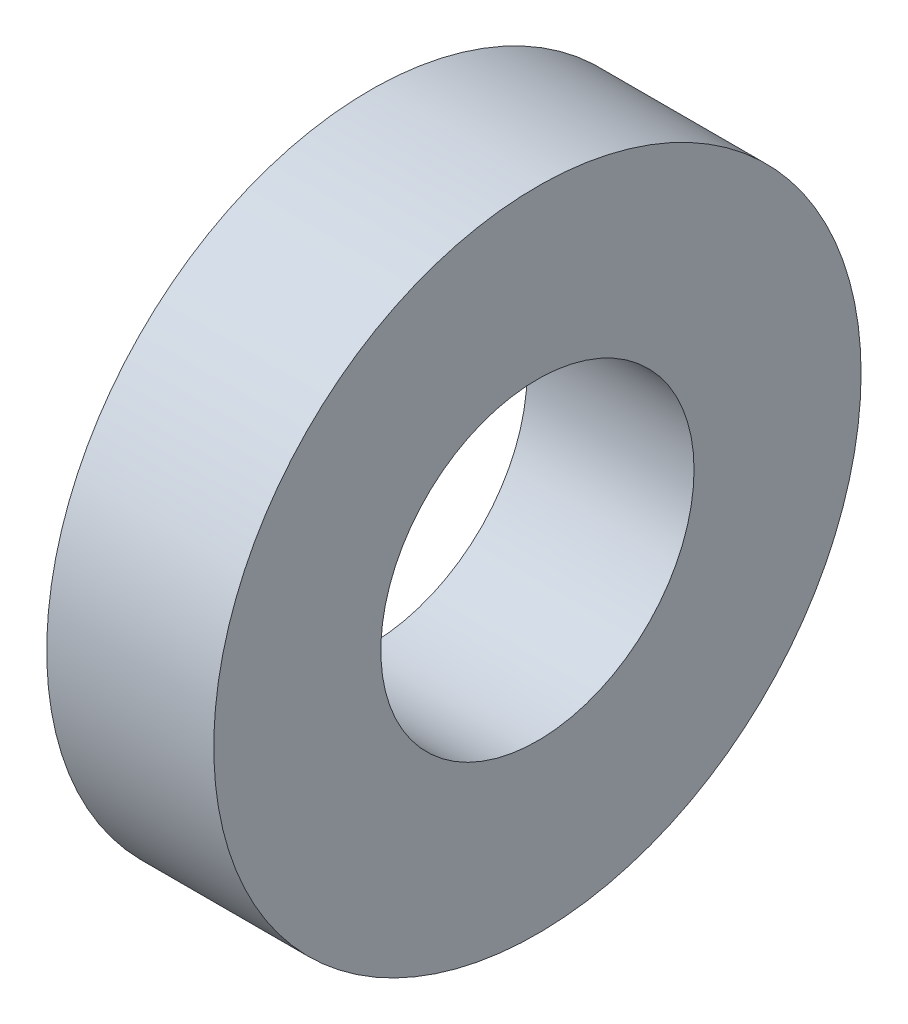
from build123d import *

# Parameters (mm, degrees)
SKETCH1_R           = 31
SKETCH1_R_2         = 15
BOSS_EXTRUDE1_DEPTH = 16


with BuildPart() as part:
    # Sketch1 → Boss-Extrude1 (new body)
    with BuildSketch(Plane(origin=(0, 0, 0), x_dir=(0, 0, -1), z_dir=(1, 0, 0))):
        Circle(SKETCH1_R)
        Circle(SKETCH1_R_2, mode=Mode.SUBTRACT)
    extrude(amount=BOSS_EXTRUDE1_DEPTH)


solid = part.part
